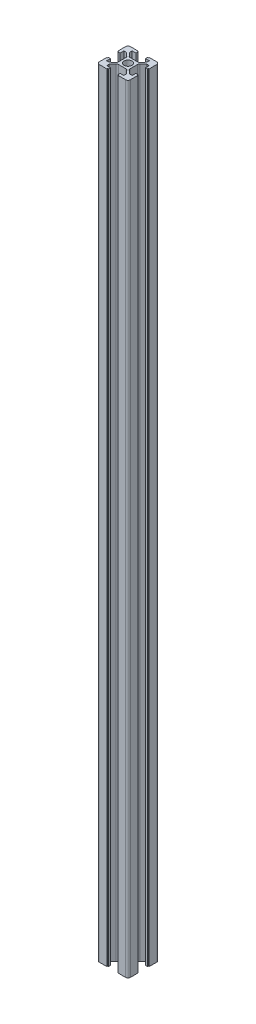
from build123d import *

# Parameters (mm, degrees)
SKETCH1_R           = 2.5
BOSS_EXTRUDE1_DEPTH = 500
SKETCH2_R           = 3
CUT_EXTRUDE1_DEPTH  = 10


with BuildPart() as part:
    # Sketch1 → Boss-Extrude1 (new body)
    with BuildSketch(Plane(origin=(0, 0, 0), x_dir=(1, 0, 0), z_dir=(0, 1, 0))):
        with BuildLine():
            ThreePointArc((-10, -8.5), (-9.560660172, -9.560660172), (-8.5, -10))
            Line((-8.5, -10), (-3.6, -10))
            Line((-3.6, -10), (-3.6, -9.5))
            Line((-3.6, -9.5), (-3.1, -9.5))
            Line((-3.1, -9.5), (-3.1, -8.2))
            Line((-3.1, -8.2), (-5.5, -8.2))
            Line((-5.5, -8.2), (-5.5, -6.6))
            Line((-5.5, -6.6), (-3.54898252, -4.32381294))
            ThreePointArc((-3.54898252, -4.32381294), (-3.036882831, -3.937230652), (-2.410097616, -3.8))
            Line((-2.410097616, -3.8), (2.410097616, -3.8))
            ThreePointArc((2.410097616, -3.8), (3.036882831, -3.937230652), (3.54898252, -4.32381294))
            Line((3.54898252, -4.32381294), (5.5, -6.6))
            Line((5.5, -6.6), (5.5, -8.2))
            Line((5.5, -8.2), (3.1, -8.2))
            Line((3.1, -8.2), (3.1, -9.5))
            Line((3.1, -9.5), (3.6, -9.5))
            Line((3.6, -9.5), (3.6, -10))
            Line((3.6, -10), (8.5, -10))
            ThreePointArc((8.5, -10), (9.560660172, -9.560660172), (10, -8.5))
            Line((10, -8.5), (10, -3.6))
            Line((10, -3.6), (9.5, -3.6))
            Line((9.5, -3.6), (9.5, -3.1))
            Line((9.5, -3.1), (8.2, -3.1))
            Line((8.2, -3.1), (8.2, -5.5))
            Line((8.2, -5.5), (6.6, -5.5))
            Line((6.6, -5.5), (4.32381294, -3.54898252))
            ThreePointArc((4.32381294, -3.54898252), (3.937230652, -3.036882831), (3.8, -2.410097616))
            Line((3.8, -2.410097616), (3.8, 2.410097616))
            ThreePointArc((3.8, 2.410097616), (3.937230652, 3.036882831), (4.32381294, 3.54898252))
            Line((4.32381294, 3.54898252), (6.6, 5.5))
            Line((6.6, 5.5), (8.2, 5.5))
            Line((8.2, 5.5), (8.2, 3.1))
            Line((8.2, 3.1), (9.5, 3.1))
            Line((9.5, 3.1), (9.5, 3.6))
            Line((9.5, 3.6), (10, 3.6))
            Line((10, 3.6), (10, 8.5))
            ThreePointArc((10, 8.5), (9.560660172, 9.560660172), (8.5, 10))
            Line((8.5, 10), (3.6, 10))
            Line((3.6, 10), (3.6, 9.5))
            Line((3.6, 9.5), (3.1, 9.5))
            Line((3.1, 9.5), (3.1, 8.2))
            Line((3.1, 8.2), (5.5, 8.2))
            Line((5.5, 8.2), (5.5, 6.6))
            Line((5.5, 6.6), (3.54898252, 4.32381294))
            ThreePointArc((3.54898252, 4.32381294), (3.036882831, 3.937230652), (2.410097616, 3.8))
            Line((2.410097616, 3.8), (-2.410097616, 3.8))
            ThreePointArc((-2.410097616, 3.8), (-3.036882831, 3.937230652), (-3.54898252, 4.32381294))
            Line((-3.54898252, 4.32381294), (-5.5, 6.6))
            Line((-5.5, 6.6), (-5.5, 8.2))
            Line((-5.5, 8.2), (-3.1, 8.2))
            Line((-3.1, 8.2), (-3.1, 9.5))
            Line((-3.1, 9.5), (-3.6, 9.5))
            Line((-3.6, 9.5), (-3.6, 10))
            Line((-3.6, 10), (-8.5, 10))
            ThreePointArc((-8.5, 10), (-9.560660172, 9.560660172), (-10, 8.5))
            Line((-10, 8.5), (-10, 3.6))
            Line((-10, 3.6), (-9.5, 3.6))
            Line((-9.5, 3.6), (-9.5, 3.1))
            Line((-9.5, 3.1), (-8.2, 3.1))
            Line((-8.2, 3.1), (-8.2, 5.5))
            Line((-8.2, 5.5), (-6.6, 5.5))
            Line((-6.6, 5.5), (-4.32381294, 3.54898252))
            ThreePointArc((-4.32381294, 3.54898252), (-3.937230652, 3.036882831), (-3.8, 2.410097616))
            Line((-3.8, 2.410097616), (-3.8, -2.410097616))
            ThreePointArc((-3.8, -2.410097616), (-3.937230652, -3.036882831), (-4.32381294, -3.54898252))
            Line((-4.32381294, -3.54898252), (-6.6, -5.5))
            Line((-6.6, -5.5), (-8.2, -5.5))
            Line((-8.2, -5.5), (-8.2, -3.1))
            Line((-8.2, -3.1), (-9.5, -3.1))
            Line((-9.5, -3.1), (-9.5, -3.6))
            Line((-9.5, -3.6), (-10, -3.6))
            Line((-10, -3.6), (-10, -8.5))
        make_face()
        Circle(SKETCH1_R, mode=Mode.SUBTRACT)
    extrude(amount=BOSS_EXTRUDE1_DEPTH)

    # Sketch2 → Cut-Extrude1 (cut)
    with BuildSketch(Plane.XY.offset(3.8)):
        with Locations((0, 450)):
            Circle(SKETCH2_R)
        with Locations((0, 370)):
            Circle(SKETCH2_R)
        with Locations((0, 290)):
            Circle(SKETCH2_R)
        with Locations((0, 210)):
            Circle(SKETCH2_R)
        with Locations((0, 130)):
            Circle(SKETCH2_R)
        with Locations((0, 50)):
            Circle(SKETCH2_R)
    extrude(amount=-CUT_EXTRUDE1_DEPTH, mode=Mode.SUBTRACT)


solid = part.part
